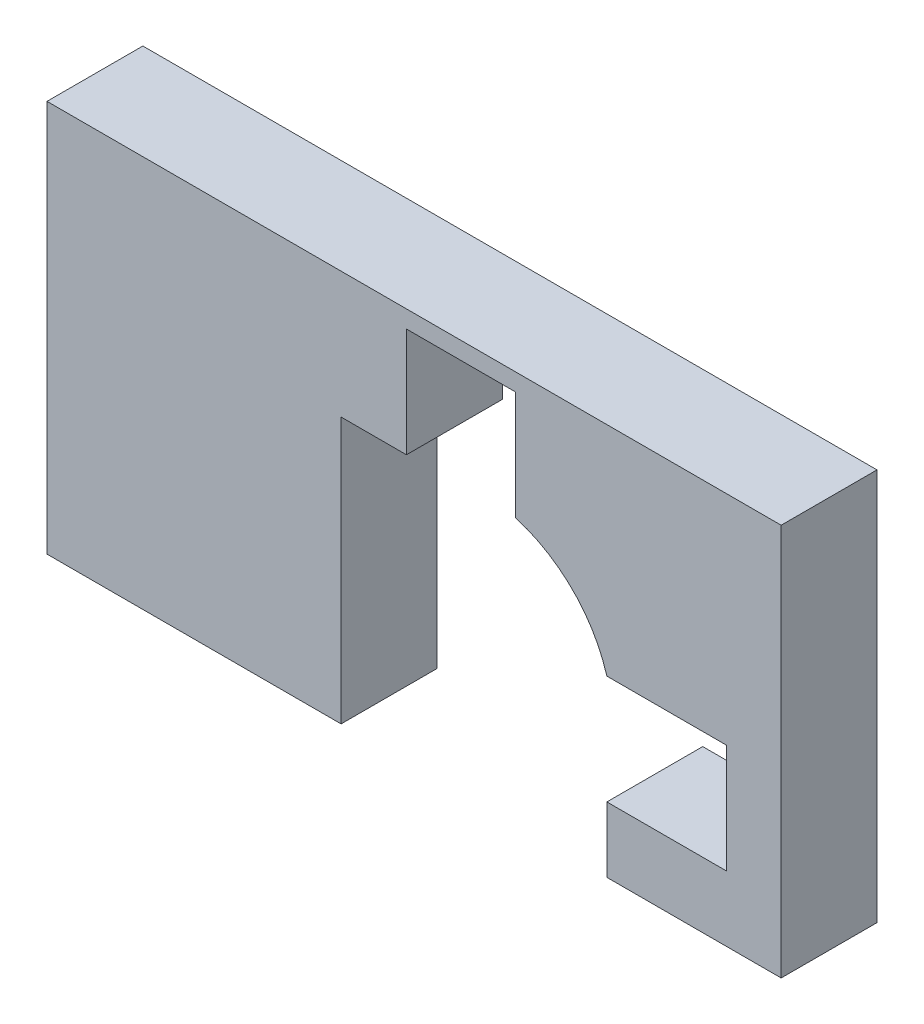
from build123d import *

# Parameters (mm, degrees)
BOSS_EXTRUDE1_DEPTH = 44


with BuildPart() as part:
    # Sketch2 → Boss-Extrude1 (new body)
    with BuildSketch(Plane.XY):
        with BuildLine():
            Line((-62.51623719, 80.614043502), (-32.51623719, 80.614043502))
            Line((-32.51623719, 80.614043502), (-32.51623719, 130.614043502))
            Line((-32.51623719, 130.614043502), (17.48376281, 130.614043502))
            Line((17.48376281, 130.614043502), (17.48376281, 80.614043502))
            ThreePointArc((17.48376281, 80.614043502), (43.840620434, 64.970901126), (59.48376281, 38.614043502))
            Line((59.48376281, 38.614043502), (114.48376281, 38.614043502))
            Line((114.48376281, 38.614043502), (114.48376281, -11.385956498))
            Line((114.48376281, -11.385956498), (59.48376281, -11.385956498))
            Line((59.48376281, -11.385956498), (59.48376281, -41.385956498))
            Line((59.48376281, -41.385956498), (139.48376281, -41.385956498))
            Line((139.48376281, -41.385956498), (139.48376281, 138.614043502))
            Line((139.48376281, 138.614043502), (-197.51623719, 138.614043502))
            Line((-197.51623719, 138.614043502), (-197.51623719, -41.385956498))
            Line((-197.51623719, -41.385956498), (-62.51623719, -41.385956498))
            Line((-62.51623719, -41.385956498), (-62.51623719, 80.614043502))
        make_face()
    extrude(amount=BOSS_EXTRUDE1_DEPTH)


solid = part.part
